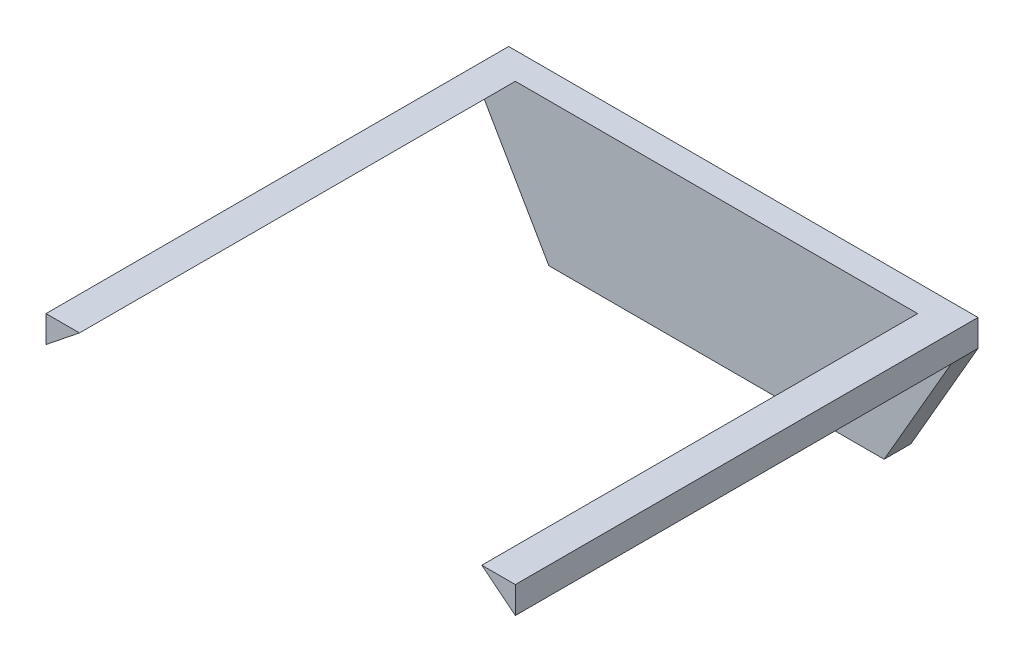
from build123d import *

# Parameters (mm, degrees)
BOSS_EXTRUDE1_DEPTH = 5.08
BOSS_EXTRUDE2_DEPTH = 82.55


with BuildPart() as part:
    # Sketch1 → Boss-Extrude1 (new body)
    with BuildSketch(Plane.XY):
        Polygon((0, 0), (-63.5, 0), (-76.2, 21.997045256), (-76.2, 27.077045256), (12.7, 27.077045256), (12.7, 21.997045256), align=None)
    extrude(amount=BOSS_EXTRUDE1_DEPTH)

    # Sketch2 → Boss-Extrude2 (add)
    with BuildSketch(Plane.XY.offset(5.08)):
        Polygon((-76.2, 21.997045256), (-69.85, 27.077045256), (-76.2, 27.077045256), align=None)
        Polygon((12.7, 21.997045256), (12.7, 27.077045256), (6.35, 27.077045256), align=None)
    extrude(amount=BOSS_EXTRUDE2_DEPTH)


solid = part.part
